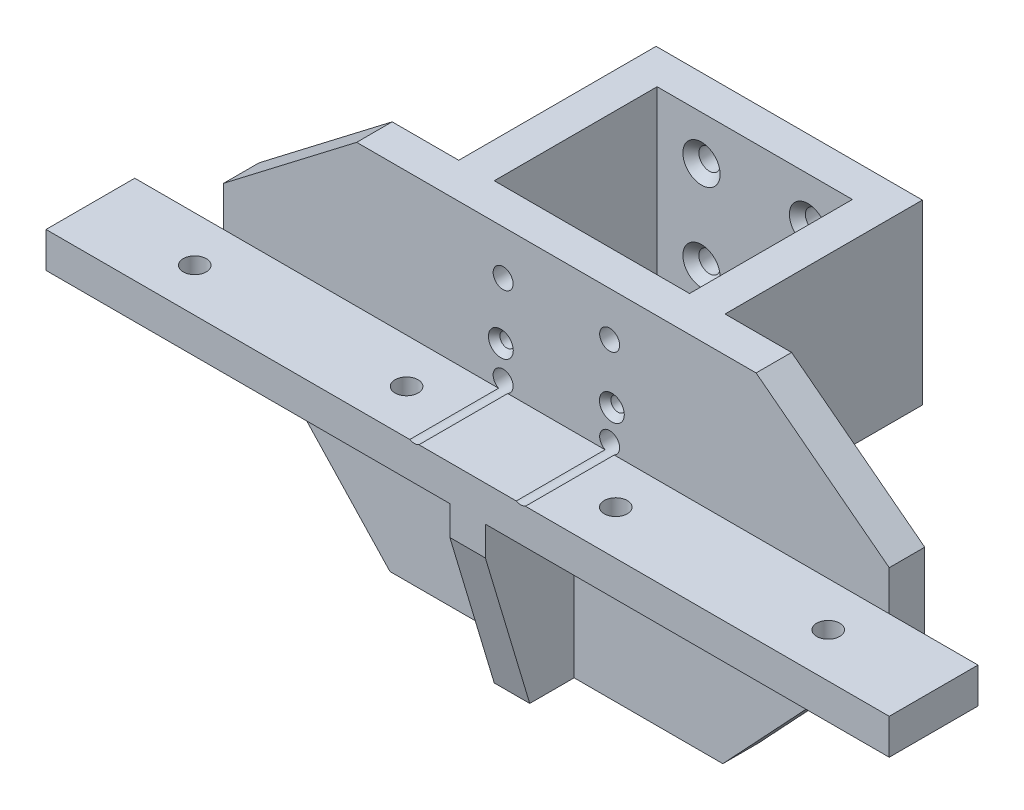
from build123d import *

# Parameters (mm, degrees)
EXTRUDE_1_DEPTH              = 8
SKETCH_2_W                   = 150
SKETCH_2_H                   = 8
EXTRUDE_2_DEPTH              = 20
SKETCH_3_W                   = 20
SKETCH_3_H                   = 8
EXTRUDE_3_DEPTH              = 20
SKETCH_4_W                   = 20
SKETCH_4_H                   = 8
EXTRUDE_4_DEPTH              = 20
SKETCH_5_W                   = 8
SKETCH_5_H                   = 40
EXTRUDE_5_DEPTH              = 20
CUT_EXTRUDE_1_DEPTH          = 20
EXTRUDE_6_DEPTH              = 40
HOLE_WIZARD_2_D              = 3.2
HOLE_WIZARD_2_DEPTH          = 8
HOLE_WIZARD_2_CSINK_D        = 5.6
HOLE_WIZARD_2_CSINK_ANGLE    = 82
HOLE_WIZARD_2_TIP            = 0.96137699
HOLE_WIZARD_M4_1_D           = 4.8
HOLE_WIZARD_M4_1_DEPTH       = 8.95
HOLE_WIZARD_M4_1_CSINK_D     = 9.4
HOLE_WIZARD_M4_1_CSINK_ANGLE = 90
SKETCH_17_R                  = 2.6
CUT_EXTRUDE_3_DEPTH          = 40
SKETCH_22_R                  = 2.25
CUT_EXTRUDE_4_DEPTH          = 74.15
SKETCH_24_W                  = 60
SKETCH_24_H                  = 0.68
CUT_EXTRUDE_5_DEPTH          = 40
SKETCH_29_W                  = 44
SKETCH_29_H                  = 0.5
CUT_EXTRUDE_10_DEPTH         = 81


with BuildPart() as part:
    # 草图1 → 凸台-拉伸1 (new body)
    with BuildSketch(Plane.XY):
        Polygon((-23.56557377, -33.278688525), (51.43442623, -33.278688525), (88.93442623, 6.721311475), (88.93442623, 23.721311475), (58.93442623, 46.721311475), (-31.06557377, 46.721311475), (-61.06557377, 23.721311475), (-61.06557377, 6.721311475), align=None)
    extrude(amount=EXTRUDE_1_DEPTH)

    # 草图2 → 凸台-拉伸2 (add)
    with BuildSketch(Plane.XY.offset(8)):
        with Locations((13.93442623, 10.721311475)):
            Rectangle(SKETCH_2_W, SKETCH_2_H)
    extrude(amount=EXTRUDE_2_DEPTH)

    # 草图3 → 凸台-拉伸3 (add)
    with BuildSketch(Plane(origin=(88.93442623, 0, 0), x_dir=(0, 0, -1), z_dir=(1, 0, 0))):
        with Locations((-18, 10.721311475)):
            Rectangle(SKETCH_3_W, SKETCH_3_H)
    extrude(amount=EXTRUDE_3_DEPTH)

    # 草图4 → 凸台-拉伸4 (add)
    with BuildSketch(Plane.ZY.offset(61.06557377)):
        with Locations((18, 10.721311475)):
            Rectangle(SKETCH_4_W, SKETCH_4_H)
    extrude(amount=EXTRUDE_4_DEPTH)

    # 草图5 → 凸台-拉伸5 (add)
    with BuildSketch(Plane.XY.offset(8)):
        with Locations((13.93442623, -13.278688525)):
            Rectangle(SKETCH_5_W, SKETCH_5_H)
    extrude(amount=EXTRUDE_5_DEPTH)

    # 草图6 → 切除-拉伸1 (cut)
    with BuildSketch(Plane(origin=(17.93442623, 0, 0), x_dir=(0, 0, -1), z_dir=(1, 0, 0))):
        Polygon((-18, -33.278688525), (-28, 0.111311475), (-28, -33.278688525), align=None)
    extrude(amount=-CUT_EXTRUDE_1_DEPTH, mode=Mode.SUBTRACT)

    # 草图7 → 凸台-拉伸6 (add)
    with BuildSketch(Plane(origin=(0, 46.721311475, 0), x_dir=(1, 0, 0), z_dir=(0, 1, 0))):
        Polygon((-8.06557377, 36.2), (35.93442623, 36.2), (35.93442623, 0), (43.93442623, 0), (43.93442623, 45.15), (-16.06557377, 45.15), (-16.06557377, 0), (-8.06557377, 0), align=None)
    extrude(amount=-EXTRUDE_6_DEPTH)

    # 孔2
    with Locations(Plane(origin=(1.420779952, 23.721311475, 8), x_dir=(1, 0, 0), z_dir=(0, 0, 1))):
        with Locations((0, 0), (25.013646278, 0), (25.013646278, -25), (0.013646278, -25)):
            CounterSinkHole(HOLE_WIZARD_2_D / 2, HOLE_WIZARD_2_CSINK_D / 2, depth=HOLE_WIZARD_2_DEPTH, counter_sink_angle=HOLE_WIZARD_2_CSINK_ANGLE)
            with Locations((0, 0, -(HOLE_WIZARD_2_DEPTH + HOLE_WIZARD_2_TIP / 2))):  # 118° drill point
                Cone(0, HOLE_WIZARD_2_D / 2, HOLE_WIZARD_2_TIP, mode=Mode.SUBTRACT)

    # M4 平头机械螺钉的锥形沉头孔1
    with Locations(Plane(origin=(1.93442623, 16.721311475, -36.2), x_dir=(1, 0, 0), z_dir=(0, 0, 1))):
        with Locations((0, 0), (24, 0), (24, 20), (0, 20)):
            CounterSinkHole(HOLE_WIZARD_M4_1_D / 2, HOLE_WIZARD_M4_1_CSINK_D / 2, depth=HOLE_WIZARD_M4_1_DEPTH, counter_sink_angle=HOLE_WIZARD_M4_1_CSINK_ANGLE)

    # 草图17 → 切除-拉伸3 (cut)
    with BuildSketch(Plane(origin=(0, 14.721311475, 0), x_dir=(1, 0, 0), z_dir=(0, 1, 0))):
        with Locations((85.18442623, -18)):
            Circle(SKETCH_17_R)
        with Locations((37.311975267, -18)):
            Circle(SKETCH_17_R)
        with Locations((-9.81557377, -18)):
            Circle(SKETCH_17_R)
        with Locations((-57.31557377, -18.235938013)):
            Circle(SKETCH_17_R)
    extrude(amount=-CUT_EXTRUDE_3_DEPTH, mode=Mode.SUBTRACT)

    # 草图22 → 切除-拉伸4 (cut, through all)
    with BuildSketch(Plane(origin=(0, 0, -45.15), x_dir=(-1, 0, 0), z_dir=(0, 0, -1))):
        with Locations((-25.93442623, 36.721311475)):
            Circle(SKETCH_22_R)
        with Locations((-1.93442623, 36.721311475)):
            Circle(SKETCH_22_R)
        with Locations((-1.93442623, 16.721311475)):
            Circle(SKETCH_22_R)
        with Locations((-25.93442623, 16.721311475)):
            Circle(SKETCH_22_R)
    extrude(amount=-CUT_EXTRUDE_4_DEPTH, mode=Mode.SUBTRACT)

    # 草图24 → 切除-拉伸5 (cut)
    with BuildSketch(Plane(origin=(0, 46.721311475, 0), x_dir=(1, 0, 0), z_dir=(0, 1, 0))):
        with Locations((13.93442623, 44.81)):
            Rectangle(SKETCH_24_W, SKETCH_24_H)
    extrude(amount=-CUT_EXTRUDE_5_DEPTH, mode=Mode.SUBTRACT)

    # 草图29 → 切除-拉伸10 (cut, through all)
    with BuildSketch(Plane(origin=(0, 46.721311475, 0), x_dir=(1, 0, 0), z_dir=(0, 1, 0))):
        with Locations((13.93442623, 36.45)):
            Rectangle(SKETCH_29_W, SKETCH_29_H)
    extrude(amount=-CUT_EXTRUDE_10_DEPTH, mode=Mode.SUBTRACT)


solid = part.part
